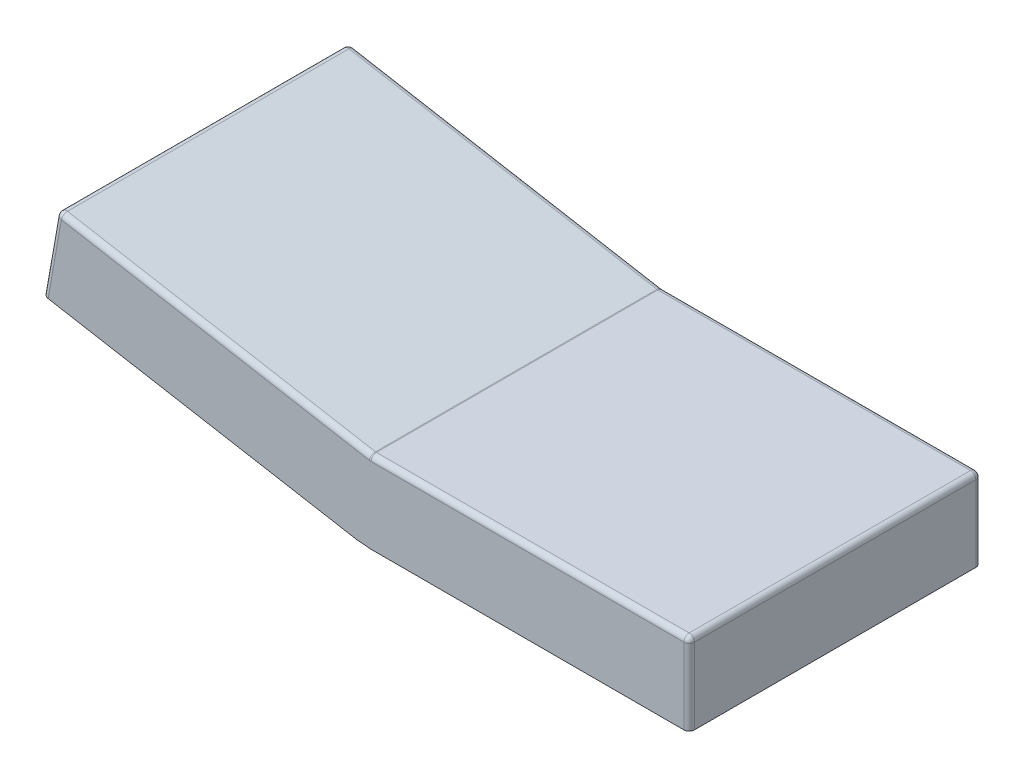
from build123d import *

# Parameters (mm, degrees)
SKETCH1_W           = 30
SKETCH1_H           = 7.657514459
BOSS_EXTRUDE1_DEPTH = 27.5
FILLET1_R           = 0.5


with BuildPart() as part:
    # Sketch1 → Boss-Extrude1 (new body)
    with BuildSketch(Plane.XY):
        Polygon((-59.54423259, 5.20944533), (-60.873946022, -2.331734278), (-31.329713431, -7.541179608), (-30, 0), align=None)
        Polygon((-30, -7.657514459), (-31.329713431, -7.541179608), (-30, 0), align=None)
        with Locations((-15, -3.82875723)):
            Rectangle(SKETCH1_W, SKETCH1_H)
    extrude(amount=BOSS_EXTRUDE1_DEPTH)

    # Fillet1
    fillet1_edges = [part.edges().sort_by_distance(p)[0] for p in [
        (-60.209089306, 1.438855526, 0),
        (-59.54423259, 5.20944533, 13.75),
        (-30, 0, 13.75),
        (0, 0, 13.75),
        (0, -3.828757229, 27.5),
        (-15, 0, 27.5),
        (-44.772116295, 2.604722665, 27.5),
        (-60.209089306, 1.438855526, 27.5),
        (-44.772116295, 2.604722665, 0),
        (-15, 0, 0),
        (0, -3.828757229, 0),
    ]]
    fillet(fillet1_edges, radius=FILLET1_R)


solid = part.part
